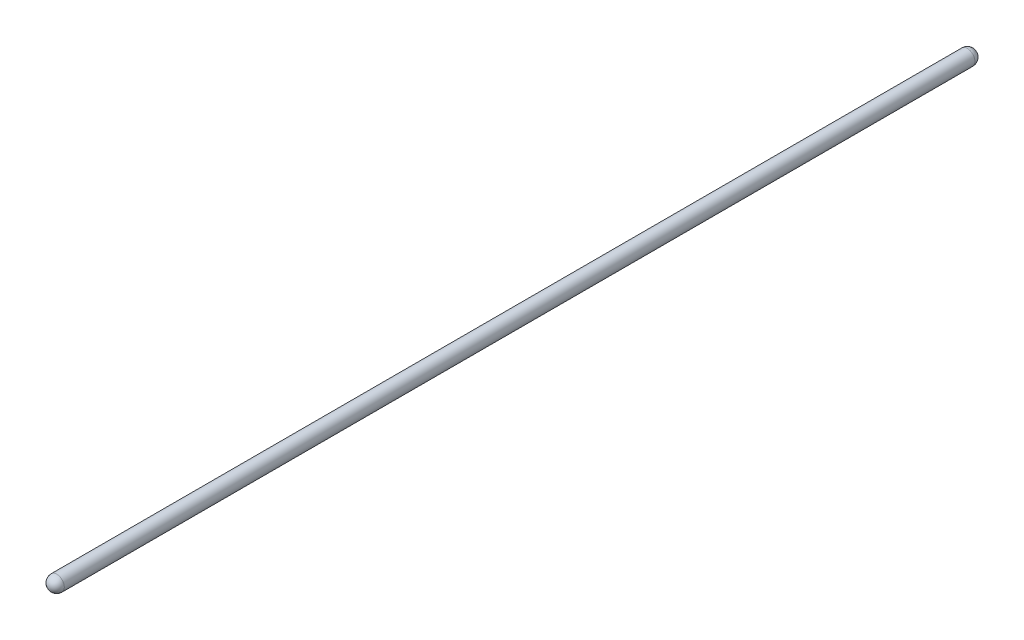
from build123d import *

# Parameters (mm, degrees)
SKETCH3_R           = 5
BOSS_EXTRUDE1_DEPTH = 300
REVOLVE3_ANGLE      = 180


with BuildPart() as part:
    # Sketch3 → Boss-Extrude1 (new body)
    with BuildSketch(Plane.XY):
        Circle(SKETCH3_R)
    boss_extrude1 = extrude(amount=BOSS_EXTRUDE1_DEPTH)

    # Sketch4 → Revolve3 (revolve)
    with BuildSketch(Plane.XY.offset(300)):
        with BuildLine():
            Line((0, 5), (0, -5))
            ThreePointArc((0, -5), (-5, 0), (0, 5))
        make_face()
    revolve3 = revolve(axis=Axis((0, 5, 300), (0, 1, 0)), revolution_arc=REVOLVE3_ANGLE)

    # Mirror2: Boss-Extrude1, Revolve3 across plane
    add(boss_extrude1.mirror(Plane.XY))
    add(revolve3.mirror(Plane.XY))


solid = part.part
